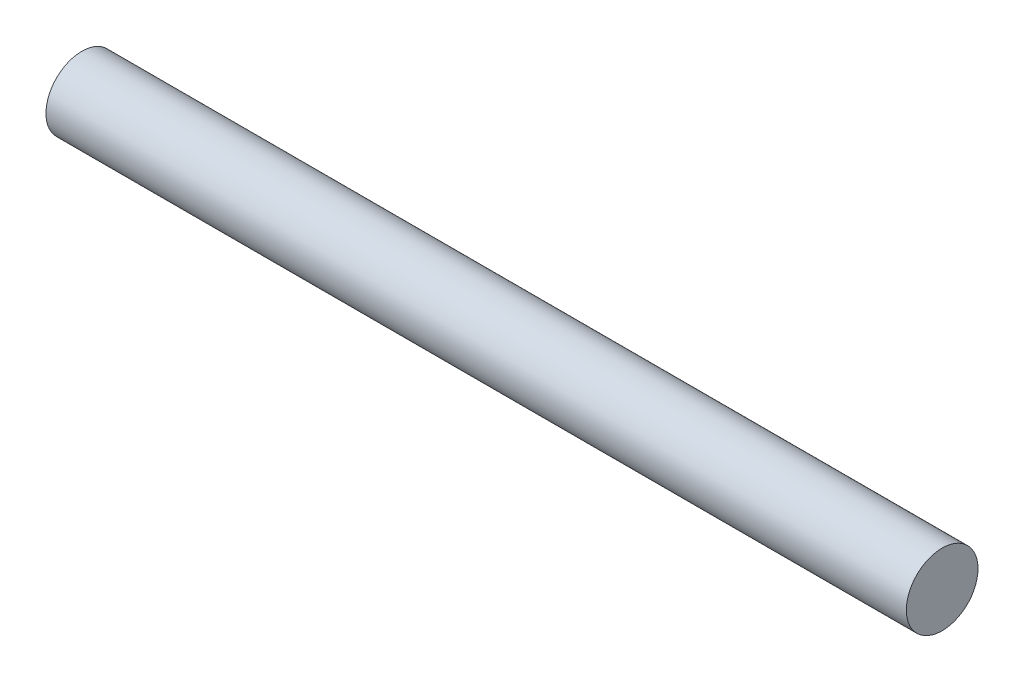
from build123d import *

# Parameters (mm, degrees)
SKETCH1_R           = 1.5875
BOSS_EXTRUDE1_DEPTH = 38.1


with BuildPart() as part:
    # Sketch1 → Boss-Extrude1 (new body)
    with BuildSketch(Plane(origin=(0, 0, 0), x_dir=(0, 0, -1), z_dir=(1, 0, 0))):
        Circle(SKETCH1_R)
    extrude(amount=BOSS_EXTRUDE1_DEPTH)


solid = part.part
